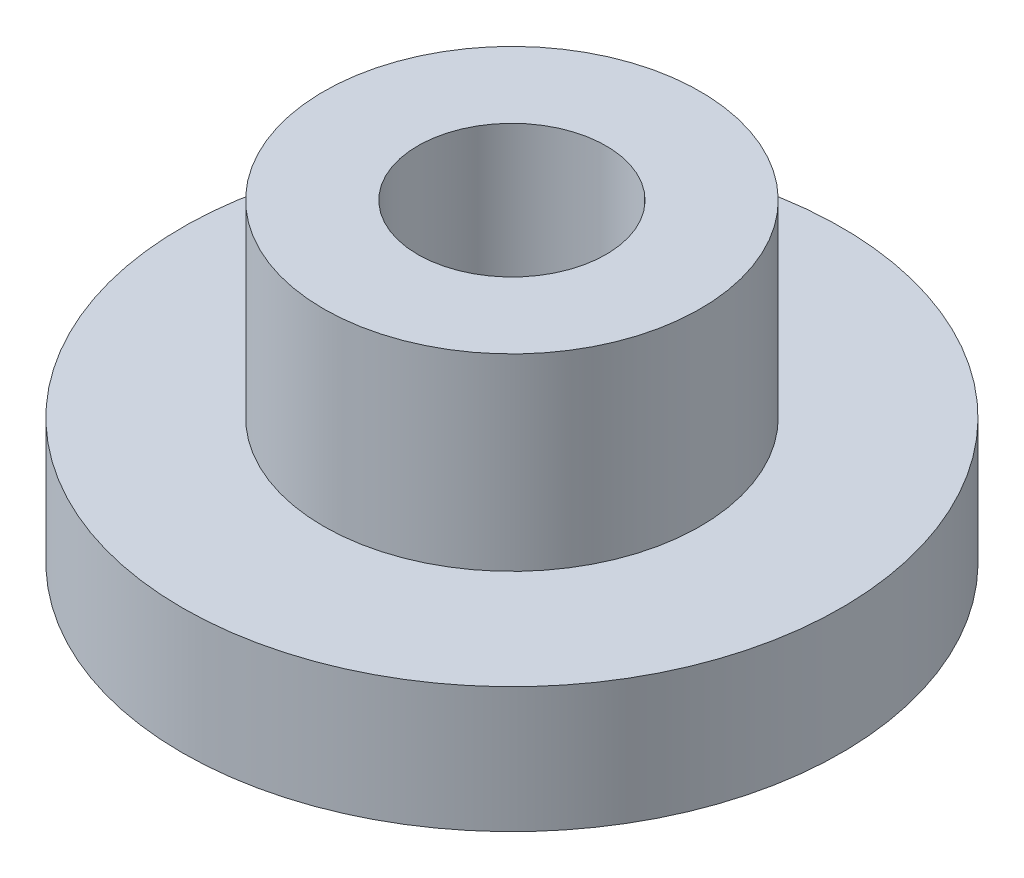
from build123d import *


with BuildPart() as part:
    # Esquisse1 → Révolution1 (revolve)
    with BuildSketch(Plane.XY):
        Polygon((0, -2), (-5.25, -2), (-5.25, 0), (-3, 0), (-3, 3), (-1.5, 3), (-1.5, 0.866025404), (0, 0), align=None)
    revolve(axis=Axis((0, 27.270256112, 0), (0, -1, 0)))


solid = part.part
